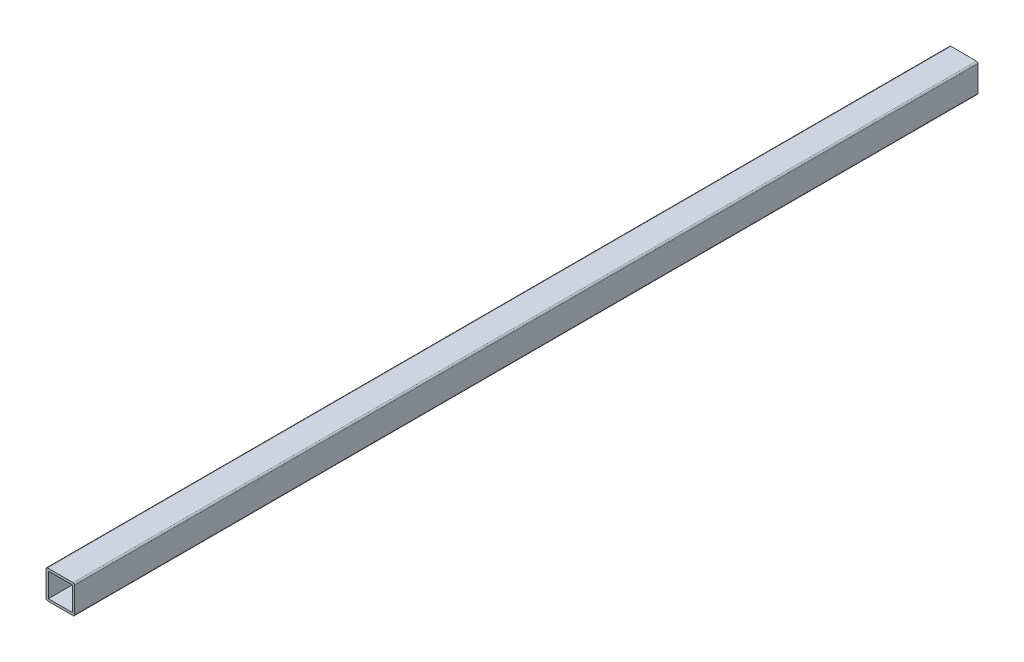
from build123d import *

# Parameters (mm, degrees)
SKETCH_1_W      = 19
SKETCH_1_H      = 19
SKETCH_1_W_2    = 15.88
SKETCH_1_H_2    = 15.88
EXTRUDE_1_DEPTH = 600
FILLET_2_R      = 1


with BuildPart() as part:
    # 스케치1 → 보스-돌출1 (new body)
    with BuildSketch(Plane.XY):
        with Locations((9.5, -9.5)):
            Rectangle(SKETCH_1_W, SKETCH_1_H)
        with Locations((9.5, -9.5)):
            Rectangle(SKETCH_1_W_2, SKETCH_1_H_2, mode=Mode.SUBTRACT)
    extrude(amount=EXTRUDE_1_DEPTH)

    # 필렛2
    fillet_2_edges = [part.edges().sort_by_distance(p)[0] for p in [
        (0, 0, 300),
        (19, 0, 300),
        (19, -19, 300),
        (0, -19, 300),
    ]]
    fillet(fillet_2_edges, radius=FILLET_2_R)


solid = part.part
